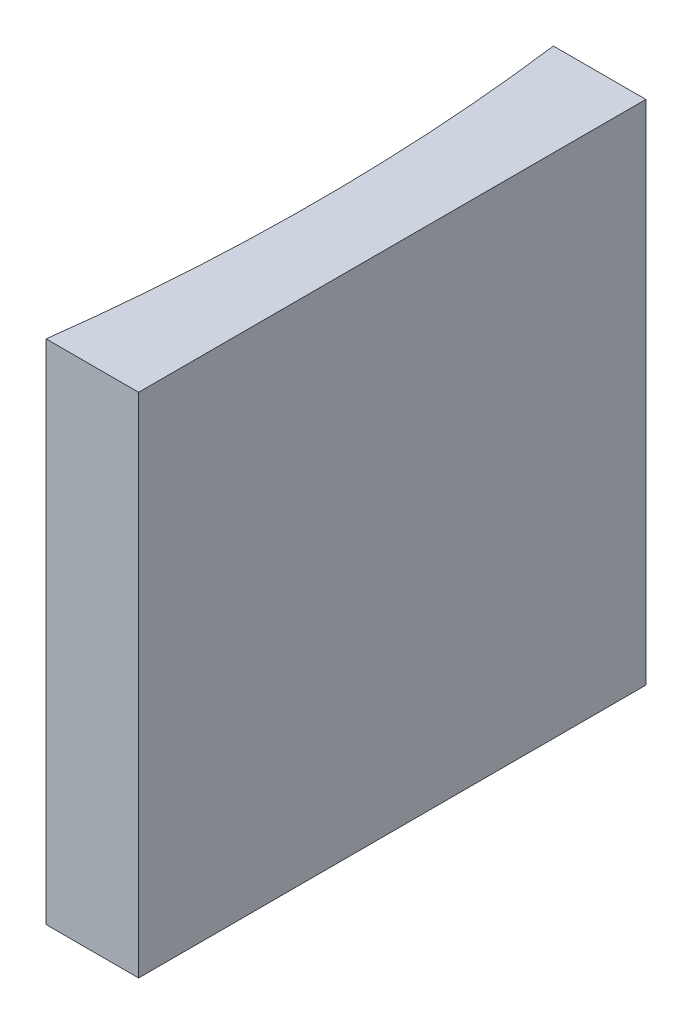
from build123d import *

# Parameters (mm, degrees)
EXTRUDE_1_DEPTH = 20


with BuildPart() as part:
    # 草图1 → 凸台-拉伸1 (new body)
    with BuildSketch(Plane(origin=(0, 0, 0), x_dir=(1, 0, 0), z_dir=(0, 1, 0))):
        with BuildLine():
            Line((0, 0), (0, -20))
            Line((0, -20), (-3.647448027, -20))
            ThreePointArc((-3.647448027, -20), (-3, -10), (-3.647448027, 0))
            Line((-3.647448027, 0), (0, 0))
        make_face()
    extrude(amount=EXTRUDE_1_DEPTH)


solid = part.part
